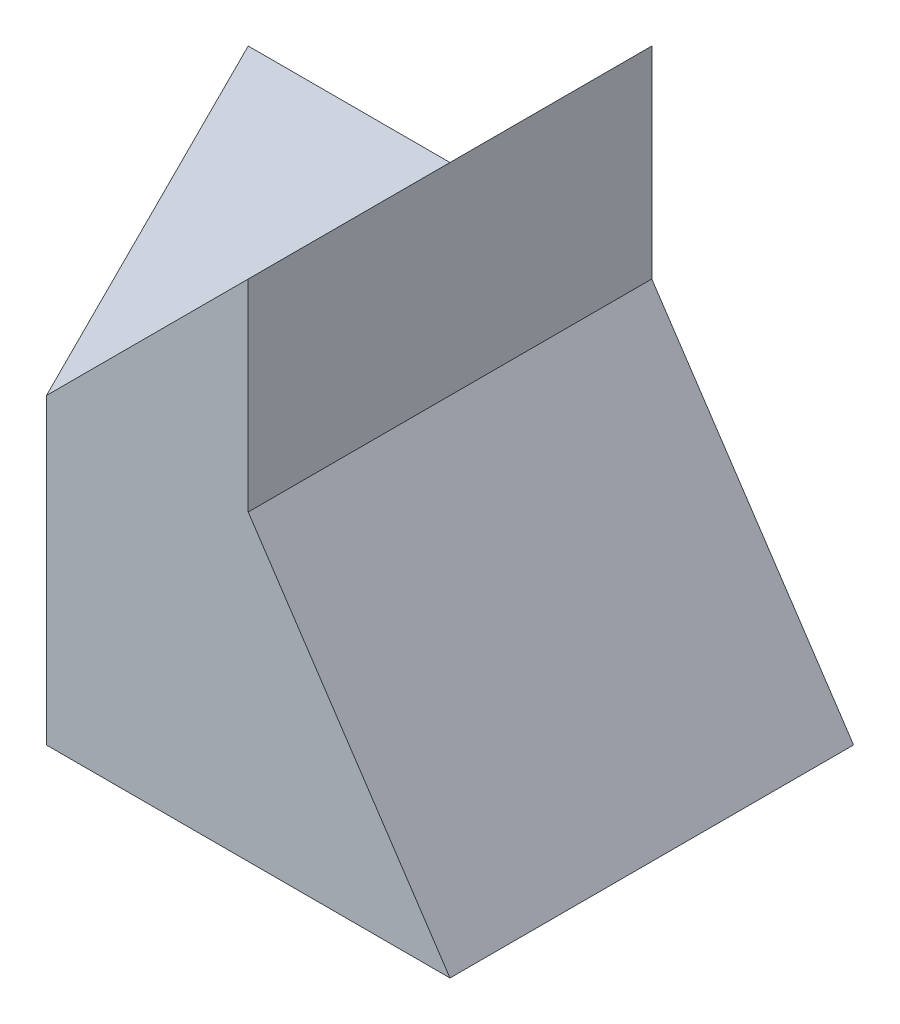
from build123d import *

# Parameters (mm, degrees)
BOSS_EXTRUDE1_DEPTH = 3
BOSS_EXTRUDE2_DEPTH = 4


with BuildPart() as part:
    # Sketch1 → Boss-Extrude1 (new body)
    with BuildSketch(Plane(origin=(0, 0, 0), x_dir=(1, 0, 0), z_dir=(0, 1, 0))):
        Polygon((0, 0), (-2, 4), (0, 4), align=None)
    extrude(amount=BOSS_EXTRUDE1_DEPTH)

    # Sketch2 → Boss-Extrude2 (add)
    with BuildSketch(Plane(origin=(0, 0, -4), x_dir=(-1, 0, 0), z_dir=(0, 0, -1))):
        Polygon((0, 3), (-2, 5), (-2, 3), (-4, 0), (0, 0), align=None)
    extrude(amount=-BOSS_EXTRUDE2_DEPTH)


solid = part.part
